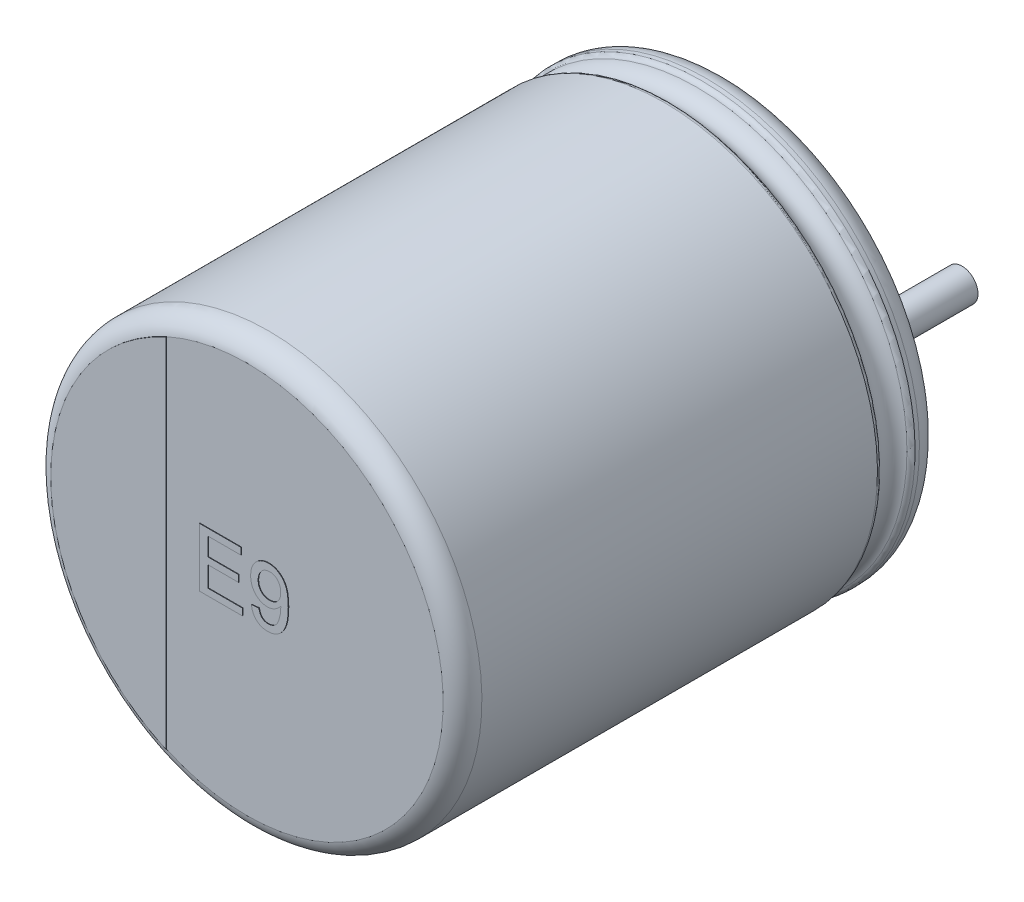
from build123d import *

# Parameters (mm, degrees)
SKETCH_2_R         = 0.3
EXTRUDE_1_DEPTH    = 2.7
EXTRUDE_2_DEPTH    = 0.01
EXTRUDE_1787_DEPTH = 0.01
EXTRUDE_5_DEPTH    = 0.05


with BuildPart() as part:
    # Sketch10 → Повернуть1 (revolve)
    with BuildSketch(Plane(origin=(0, 0, 0), x_dir=(0, 0, -1), z_dir=(1, 0, 0))):
        with BuildLine():
            Line((-9, 0), (-0.05, 0))
            Line((-0.05, 0), (-0.05, 3.403143426))
            ThreePointArc((-0.05, 3.403143426), (-0.052704561, 3.801565585), (-0.398206102, 4))
            Line((-0.398206102, 4), (-0.479422929, 4))
            ThreePointArc((-0.479422929, 4), (-0.534479696, 3.983479053), (-0.571344666, 3.939375046))
            ThreePointArc((-0.571344666, 3.939375046), (-0.831990181, 3.767472047), (-1.092635697, 3.939375046))
            ThreePointArc((-1.092635697, 3.939375046), (-1.129500666, 3.983479053), (-1.184557434, 4))
            Line((-1.184557434, 4), (-8.6, 4))
            ThreePointArc((-8.6, 4), (-8.85971595, 3.909961924), (-9, 3.67357323))
            Line((-9, 3.67357323), (-9, 0))
        make_face()
    revolve(axis=Axis((0, 0, -18.1630778), (0, 0, 1)))

    # Эскиз2 → Бобышка-Вытянуть1 (add)
    with BuildSketch(Plane(origin=(0, 0, 0.05), x_dir=(-1, 0, 0), z_dir=(0, 0, -1))):
        with Locations(Location((-1.75, 0, 0), (0, 0, 90))):
            Circle(SKETCH_2_R)
        with Locations(Location((1.75, 0, 0), (0, 0, 270))):
            Circle(SKETCH_2_R)
    extrude(amount=EXTRUDE_1_DEPTH)

    # Эскиз4 → Бобышка-Вытянуть2 (add)
    with BuildSketch(Plane.XY.offset(9)):
        with BuildLine():
            Line((-1.509635526, -3.349050739), (-1.509635526, 3.349050739))
            ThreePointArc((-1.509635526, 3.349050739), (-3.67357323, 0), (-1.509635526, -3.349050739))
        make_face()
    extrude(amount=EXTRUDE_2_DEPTH)

    # Эскиз5 → Extrude 1787 (add)
    with BuildSketch(Plane.XY.offset(9)):
        Polygon((-0.884369756, -0.464160183), (-0.884369756, 0.635839817), (-0.108728731, 0.635839817), (-0.108728731, 0.50891674), (-0.729241551, 0.50891674), (-0.729241551, 0.170455202), (-0.151036423, 0.170455202), (-0.151036423, 0.043532125), (-0.729241551, 0.043532125), (-0.729241551, -0.337237106), (-0.080523602, -0.337237106), (-0.080523602, -0.464160183), align=None)
        with BuildLine():
            Line((0.088707167, -0.196211465), (0.229732808, -0.182108901))
            add(Edge.make_bspline(
                [(0.229732808, -0.182108901), (0.231007764, -0.1893345), (0.233472362, -0.203302195), (0.239034183, -0.223208554), (0.244675233, -0.241769307), (0.25195707, -0.258570963), (0.259540572, -0.274069902), (0.268128679, -0.288110814), (0.277874404, -0.30041169), (0.291636647, -0.314826124), (0.311163267, -0.329867831), (0.338229808, -0.3420522), (0.368005545, -0.350244611), (0.388989241, -0.350966307), (0.399844987, -0.35133967)],
                knots=[0, 0, 0, 0, 0.994516507, 1.922484754, 2.80151264, 3.623050913, 4.402748861, 5.140924173, 5.850441436, 6.526872911, 7.841975818, 9.161260782, 10.53140107, 12, 12, 12, 12], degree=3))
            add(Edge.make_bspline(
                [(0.399844987, -0.35133967), (0.409343871, -0.350997607), (0.428039147, -0.350324373), (0.455297478, -0.34510541), (0.481219727, -0.336744741), (0.50535466, -0.324748932), (0.527614438, -0.310150368), (0.547057604, -0.292804332), (0.563943784, -0.273457898), (0.577812583, -0.251167094), (0.589649977, -0.225707254), (0.600834741, -0.196754582), (0.611415341, -0.163810274), (0.620818757, -0.127294523), (0.629239056, -0.088540454), (0.63514834, -0.04842619), (0.638784092, -0.007731618), (0.639173035, 0.01965303), (0.639368225, 0.033395907)],
                knots=[0, 0, 0, 0, 0.897794352, 1.766998465, 2.614902619, 3.466100941, 4.308008728, 5.124841802, 5.922729683, 6.728261092, 7.598214292, 8.574707161, 9.662086263, 10.868425066, 12.139522319, 13.41071447, 14.70057738, 16, 16, 16, 16], degree=3))
            add(Edge.make_bspline(
                [(0.639368225, 0.033395907), (0.639301472, 0.03714206), (0.639141769, 0.046104514), (0.638867055, 0.055064219), (0.638707167, 0.06027892)],
                knots=[0, 0, 0, 0, 0.835966126, 2, 2, 2, 2], degree=3))
            add(Edge.make_bspline(
                [(0.638707167, 0.06027892), (0.631908544, 0.049954718), (0.618322254, 0.029322949), (0.593292952, 0.001632619), (0.564658991, -0.02292908), (0.532855015, -0.044171424), (0.498666338, -0.061604593), (0.462687736, -0.07427224), (0.425229358, -0.082094346), (0.399735787, -0.082955489), (0.386844186, -0.083390952)],
                knots=[0, 0, 0, 0, 0.978840568, 1.956103883, 2.947027447, 3.962820877, 4.980997961, 5.980964245, 6.979013046, 8, 8, 8, 8], degree=3))
            add(Edge.make_bspline(
                [(0.386844186, -0.083390952), (0.376101142, -0.083112612), (0.354953253, -0.082564693), (0.323975317, -0.077694966), (0.294180614, -0.070392103), (0.265851483, -0.059335214), (0.238547162, -0.045660687), (0.212554346, -0.028876254), (0.187832984, -0.00900476), (0.164702515, 0.013706361), (0.143593927, 0.039020877), (0.124978588, 0.066322079), (0.109520436, 0.09574346), (0.096658718, 0.1269178), (0.086734549, 0.160146307), (0.079838551, 0.195351121), (0.075200661, 0.232397858), (0.074805924, 0.25777361), (0.074604603, 0.270715618)],
                knots=[0, 0, 0, 0, 0.975490236, 1.920271282, 2.842894855, 3.757591483, 4.67685385, 5.613562631, 6.563069669, 7.554119451, 8.55387214, 9.553424333, 10.550567425, 11.568071726, 12.613215376, 13.695622473, 14.824733476, 16, 16, 16, 16], degree=3))
            add(Edge.make_bspline(
                [(0.074604603, 0.270715618), (0.07490613, 0.28409603), (0.07549597, 0.310270437), (0.079951498, 0.34854067), (0.087322767, 0.384796954), (0.098072745, 0.418970084), (0.111366875, 0.451279632), (0.128130256, 0.481492653), (0.147717399, 0.50973839), (0.170245338, 0.535744529), (0.195003338, 0.559079234), (0.221289166, 0.579905865), (0.249445349, 0.597025256), (0.278932013, 0.611298557), (0.309972309, 0.62232918), (0.342513182, 0.630302002), (0.37664468, 0.634980205), (0.39990399, 0.635549845), (0.411744026, 0.635839817)],
                knots=[0, 0, 0, 0, 1.151671969, 2.252870106, 3.311924673, 4.331900944, 5.332425074, 6.314476151, 7.300265758, 8.286521684, 9.270545387, 10.225535917, 11.167946231, 12.101233205, 13.04124339, 13.998220545, 14.981004193, 16, 16, 16, 16], degree=3))
            add(Edge.make_bspline(
                [(0.411744026, 0.635839817), (0.420343303, 0.6356659), (0.437435791, 0.63532021), (0.462872962, 0.632680981), (0.487707784, 0.627923339), (0.512102177, 0.621917858), (0.535644676, 0.613581797), (0.5587891, 0.603941997), (0.581256292, 0.592151791), (0.603177167, 0.578744851), (0.624414045, 0.563956843), (0.643953196, 0.546967023), (0.66257559, 0.528936839), (0.679902286, 0.509300421), (0.695385241, 0.487754714), (0.710075589, 0.465061467), (0.723265181, 0.440725503), (0.735293174, 0.414713863), (0.745998553, 0.386491107), (0.754929522, 0.355433542), (0.762585355, 0.321433597), (0.768959591, 0.284446204), (0.77368619, 0.244497733), (0.777164692, 0.201647555), (0.779441917, 0.155863077), (0.779633939, 0.124330906), (0.779732808, 0.108095426)],
                knots=[0, 0, 0, 0, 0.850689348, 1.69088598, 2.526071361, 3.350886897, 4.173587108, 4.994166539, 5.82944675, 6.680632524, 7.535501428, 8.385942454, 9.238956306, 10.098905971, 10.972410977, 11.861345628, 12.77184846, 13.708225841, 14.694799433, 15.754852217, 16.902446579, 18.141290626, 19.466225842, 20.880733292, 22.39393263, 24, 24, 24, 24], degree=3))
            add(Edge.make_bspline(
                [(0.779732808, 0.108095426), (0.779633277, 0.091125553), (0.779439295, 0.058051954), (0.777144192, 0.009772892), (0.773667439, -0.035865234), (0.768937499, -0.078892395), (0.762518828, -0.119242921), (0.754889726, -0.156909759), (0.7458925, -0.191962449), (0.73531945, -0.224404067), (0.723299935, -0.254607435), (0.710130097, -0.282944461), (0.695380607, -0.309373241), (0.679217192, -0.33394446), (0.6618474, -0.356701065), (0.643000029, -0.377582093), (0.622668959, -0.396524426), (0.601113346, -0.413741239), (0.57836554, -0.428913576), (0.554735216, -0.442301276), (0.529955693, -0.453268145), (0.504281712, -0.462264971), (0.477758894, -0.469693311), (0.450171207, -0.474698539), (0.421646107, -0.47753333), (0.402348502, -0.478017495), (0.392573353, -0.478262747)],
                knots=[0, 0, 0, 0, 1.538356107, 2.998194159, 4.380716326, 5.687456969, 6.921258146, 8.08355215, 9.170518603, 10.200253214, 11.174652363, 12.115998813, 13.031191965, 13.915860606, 14.780247615, 15.624154577, 16.462764255, 17.29681422, 18.1223677, 18.939254916, 19.756006416, 20.575278551, 21.404021733, 22.250368457, 23.113728878, 24, 24, 24, 24], degree=3))
            add(Edge.make_bspline(
                [(0.392573353, -0.478262747), (0.382205096, -0.478083479), (0.361919558, -0.47773274), (0.332304761, -0.474044699), (0.304092735, -0.468437673), (0.277365587, -0.460160376), (0.251923156, -0.449971246), (0.228199696, -0.436950116), (0.205773609, -0.421927629), (0.184921564, -0.404600841), (0.165887711, -0.385033383), (0.148665712, -0.363707502), (0.133567092, -0.34034699), (0.120670869, -0.315089574), (0.109247807, -0.288147747), (0.100391827, -0.259160235), (0.093197195, -0.228394389), (0.090228012, -0.20711234), (0.088707167, -0.196211465)],
                knots=[0, 0, 0, 0, 1.08199657, 2.11693069, 3.111083497, 4.081436044, 5.034173265, 5.967546613, 6.901297947, 7.84883568, 8.792454994, 9.747011506, 10.706361727, 11.690764787, 12.70483191, 13.757514363, 14.851376857, 16, 16, 16, 16], degree=3))
        make_face()
        with BuildLine():
            add(Edge.make_bspline(
                [(0.638707167, 0.273800554), (0.638548556, 0.282621654), (0.638239831, 0.29979136), (0.635535023, 0.324841747), (0.631183005, 0.348431771), (0.625074627, 0.370697077), (0.616779267, 0.391401645), (0.607169659, 0.411028872), (0.595418074, 0.429034748), (0.582158475, 0.445661736), (0.567552759, 0.460534194), (0.551647268, 0.473501647), (0.53474022, 0.484617693), (0.51642601, 0.493357896), (0.497306687, 0.500559791), (0.476922978, 0.50526667), (0.455555361, 0.508563932), (0.440844003, 0.508797552), (0.433338577, 0.50891674)],
                knots=[0, 0, 0, 0, 1.20361398, 2.342757417, 3.433960756, 4.474970456, 5.487648377, 6.473933575, 7.452701285, 8.415527761, 9.372491588, 10.291530068, 11.211879743, 12.12647906, 13.055739058, 13.994253148, 14.97671008, 16, 16, 16, 16], degree=3))
            add(Edge.make_bspline(
                [(0.433338577, 0.50891674), (0.425618556, 0.508682803), (0.410410096, 0.508221945), (0.388119072, 0.505254001), (0.366978782, 0.499571302), (0.346846505, 0.492033331), (0.327498644, 0.482708993), (0.309638569, 0.470491261), (0.292518238, 0.456645542), (0.276824321, 0.440582664), (0.262488446, 0.422971454), (0.249856959, 0.403977213), (0.239219647, 0.383590634), (0.230716443, 0.361896715), (0.22376736, 0.339084542), (0.218993834, 0.314950138), (0.216056616, 0.289519197), (0.215774486, 0.272119457), (0.215630244, 0.263223631)],
                knots=[0, 0, 0, 0, 1.007165334, 1.984118292, 2.925321257, 3.856078893, 4.785899085, 5.718627206, 6.671847665, 7.654235469, 8.641842333, 9.630378272, 10.624608936, 11.635186472, 12.665777387, 13.731187195, 14.840042241, 16, 16, 16, 16], degree=3))
            add(Edge.make_bspline(
                [(0.215630244, 0.263223631), (0.215763462, 0.255279354), (0.216024652, 0.239703716), (0.219135138, 0.21697249), (0.223284063, 0.195277611), (0.229898235, 0.174840529), (0.237866391, 0.155364538), (0.248222542, 0.137296932), (0.259882583, 0.120097454), (0.273544578, 0.10434229), (0.288647943, 0.090049594), (0.305143883, 0.077591971), (0.322824037, 0.06692803), (0.341852662, 0.058345068), (0.362115645, 0.051734926), (0.383567756, 0.046868527), (0.406302243, 0.04396998), (0.421871774, 0.043680018), (0.429812936, 0.043532125)],
                knots=[0, 0, 0, 0, 1.102204012, 2.160993585, 3.181057555, 4.164839289, 5.138418409, 6.097303793, 7.050641095, 8.019669129, 8.986440483, 9.932879371, 10.884360123, 11.847412593, 12.824617322, 13.839006415, 14.897795988, 16, 16, 16, 16], degree=3))
            add(Edge.make_bspline(
                [(0.429812936, 0.043532125), (0.437240492, 0.043681463), (0.451859583, 0.043975395), (0.473275015, 0.046886299), (0.493623701, 0.051761723), (0.512997005, 0.058390066), (0.531363525, 0.06697006), (0.548599758, 0.077718746), (0.565038892, 0.090034011), (0.580199033, 0.104423797), (0.594054848, 0.120356105), (0.606037551, 0.13798833), (0.616270137, 0.157000268), (0.624324223, 0.177617273), (0.630775164, 0.199585512), (0.635317055, 0.223044071), (0.63829146, 0.247942871), (0.638566502, 0.265050968), (0.638707167, 0.273800554)],
                knots=[0, 0, 0, 0, 1.017004716, 2.00169281, 2.953445817, 3.879374072, 4.80207141, 5.723561102, 6.657273834, 7.611045633, 8.581233951, 9.544037932, 10.525327521, 11.53237926, 12.57032081, 13.657564536, 14.802009319, 16, 16, 16, 16], degree=3))
        make_face(mode=Mode.SUBTRACT)
    extrude(amount=EXTRUDE_1787_DEPTH)

    # Эскиз6 → Бобышка-Вытянуть5 (add)
    with BuildSketch(Plane(origin=(0, 0, 0.05), x_dir=(-1, 0, 0), z_dir=(0, 0, -1))):
        with BuildLine():
            Line((-1.75, 0.465643654), (-2.133155916, 0.465643654))
            ThreePointArc((-2.133155916, 0.465643654), (-2.336107869, 0.569662474), (-2.37017324, 0.795159615))
            ThreePointArc((-2.37017324, 0.795159615), (0, 2.5), (2.37017324, 0.795159615))
            ThreePointArc((2.37017324, 0.795159615), (2.336107869, 0.569662474), (2.133155916, 0.465643654))
            Line((2.133155916, 0.465643654), (1.75, 0.465643654))
            ThreePointArc((1.75, 0.465643654), (1.284356346, 0), (1.75, -0.465643654))
            Line((1.75, -0.465643654), (2.133155916, -0.465643654))
            ThreePointArc((2.133155916, -0.465643654), (2.336107869, -0.569662474), (2.37017324, -0.795159615))
            ThreePointArc((2.37017324, -0.795159615), (0, -2.5), (-2.37017324, -0.795159615))
            ThreePointArc((-2.37017324, -0.795159615), (-2.336107869, -0.569662474), (-2.133155916, -0.465643654))
            Line((-2.133155916, -0.465643654), (-1.75, -0.465643654))
            ThreePointArc((-1.75, -0.465643654), (-1.284356346, 0), (-1.75, 0.465643654))
        make_face()
    extrude(amount=EXTRUDE_5_DEPTH)


solid = part.part
